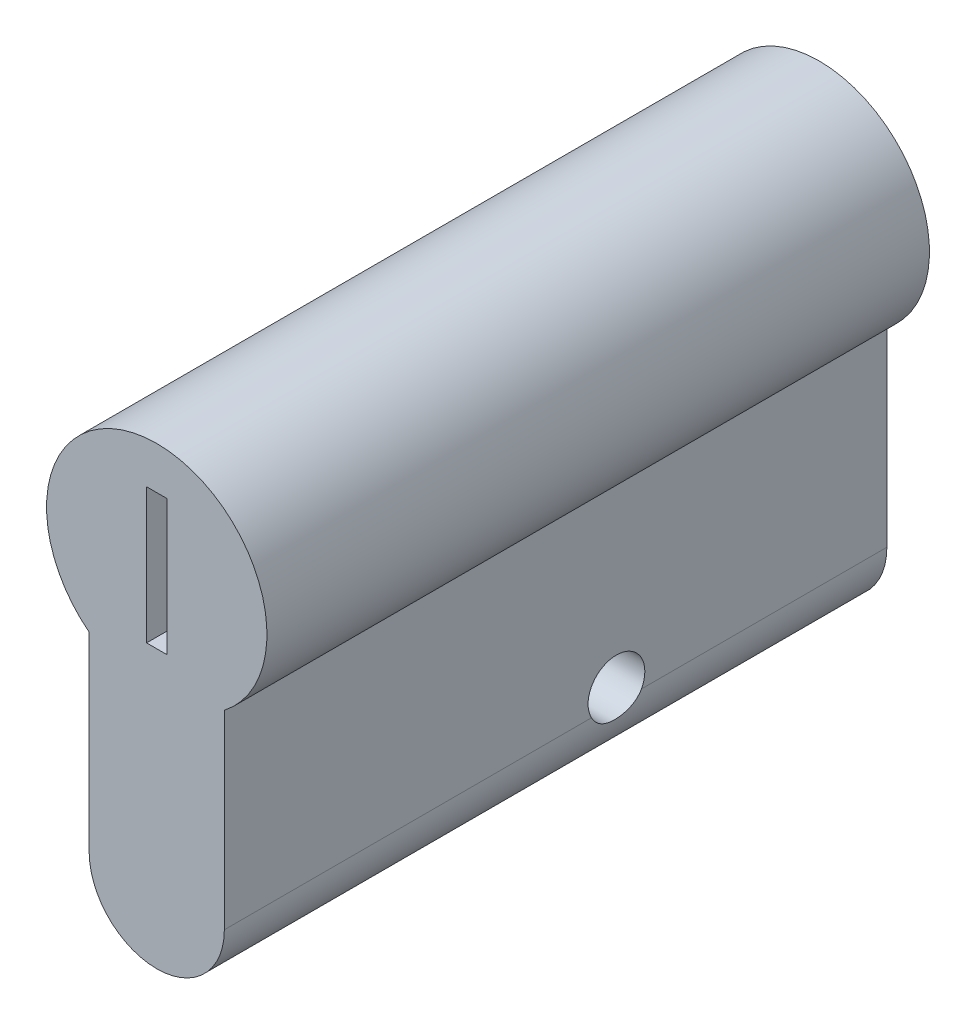
from build123d import *

# Parameters (mm, degrees)
ESQUISSE2_W           = 1.5
ESQUISSE2_H           = 10
EXTRUSION2_DEPTH      = 9
EXTRUSION2_DEPTH_BACK = 40
TROU_TARAUD_M51_D     = 4.2


with BuildPart() as part:
    # Esquisse2 → Extrusion2 (new body, two sides)
    with BuildSketch(Plane.XY.offset(17.5)) as extrusion2_sk:
        with BuildLine():
            Line((-5, -6.436031386), (-5, -20.5))
            ThreePointArc((-5, -20.5), (0, -25.5), (5, -20.5))
            Line((5, -20.5), (5, -6.436031386))
            ThreePointArc((5, -6.436031386), (0, 8.15), (-5, -6.436031386))
        make_face()
        Rectangle(ESQUISSE2_W, ESQUISSE2_H, mode=Mode.SUBTRACT)
    extrude(amount=EXTRUSION2_DEPTH)
    extrude(extrusion2_sk.sketch, amount=-EXTRUSION2_DEPTH_BACK)

    # Trou taraudé M51 (through all)
    with Locations(Plane(origin=(-5, -19.5, -2.5), x_dir=(0, -1, 0), z_dir=(-1, 0, 0))):
        with Locations((0, 0)):
            Hole(TROU_TARAUD_M51_D / 2)


solid = part.part
